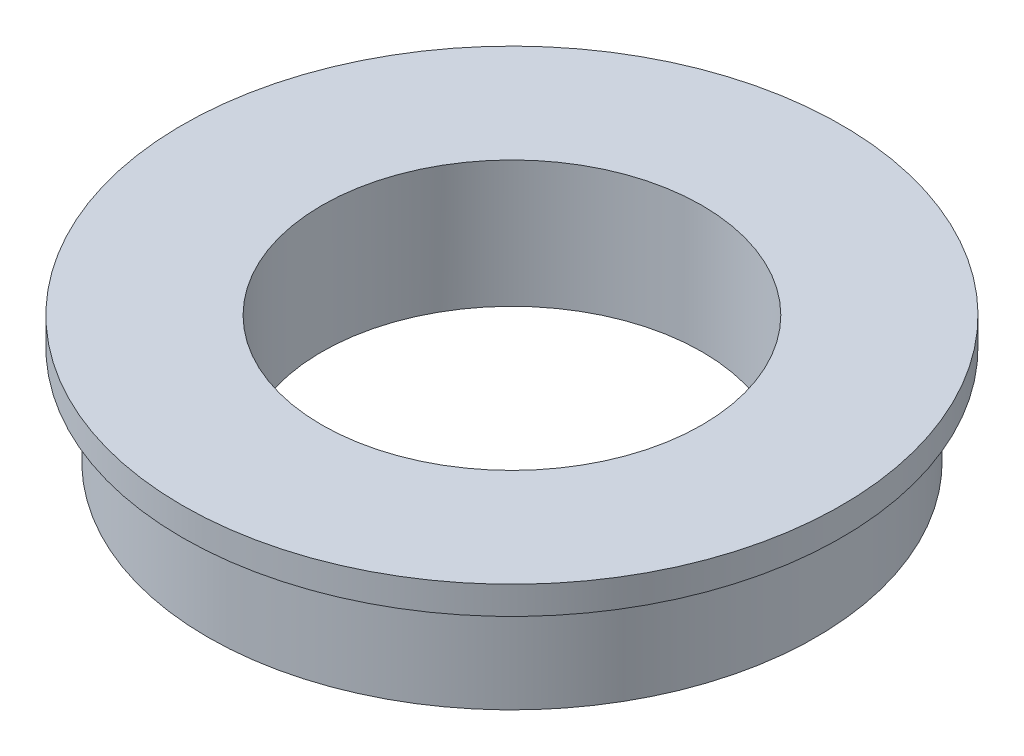
from build123d import *

# Parameters (mm, degrees)
SKETCH_1_R          = 12
EXTRUDE_1_DEPTH     = 3.9
SKETCH_2_R          = 13
EXTRUDE_2_DEPTH     = 1.1
SKETCH_3_R          = 7.5
CUT_EXTRUDE_1_DEPTH = 5


with BuildPart() as part:
    # 草图1 → 凸台-拉伸1 (new body)
    with BuildSketch(Plane(origin=(0, 0, 0), x_dir=(1, 0, 0), z_dir=(0, 1, 0))):
        Circle(SKETCH_1_R)
    extrude(amount=EXTRUDE_1_DEPTH)

    # 草图2 → 凸台-拉伸2 (add)
    with BuildSketch(Plane(origin=(0, 3.9, 0), x_dir=(1, 0, 0), z_dir=(0, 1, 0))):
        Circle(SKETCH_2_R)
    extrude(amount=EXTRUDE_2_DEPTH)

    # 草图3 → 切除-拉伸1 (cut)
    with BuildSketch(Plane.XZ):
        Circle(SKETCH_3_R)
    extrude(amount=-CUT_EXTRUDE_1_DEPTH, mode=Mode.SUBTRACT)


solid = part.part
